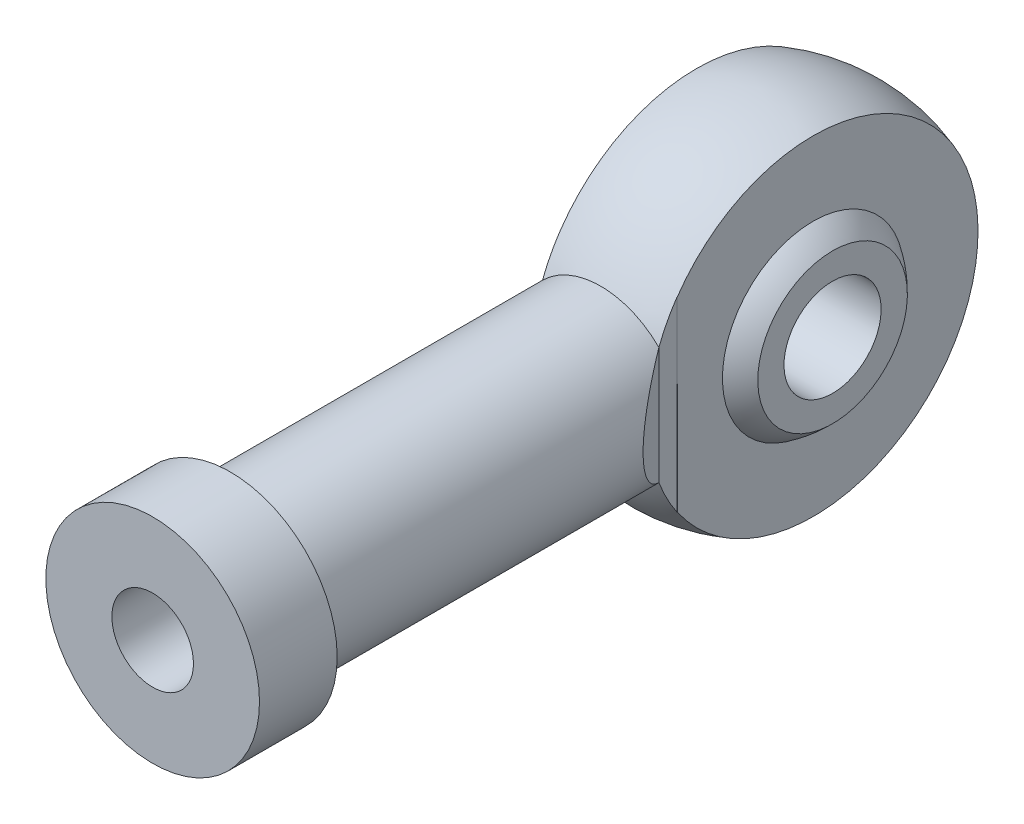
from build123d import *

# Parameters (mm, degrees)
SKETCH_3_R             = 5.5
EXTRUDE_2_DEPTH        = 4
SKETCH_4_R             = 4.25
EXTRUDE_3_DEPTH        = 20
CUT_EXTRUDE_1_DEPTH    = 10
HOLE_WIZARD_M5_1_D     = 4.2
HOLE_WIZARD_M5_1_DEPTH = 12.4
HOLE_WIZARD_M5_1_TIP   = 1.2618073


with BuildPart() as part:
    # 草图1 → 旋转1 (revolve)
    with BuildSketch(Plane.XY):
        with BuildLine():
            Line((-4, 3.854610875), (-4, 2.495599217))
            Line((-4, 2.495599217), (4, 2.504403811))
            Line((4, 2.504403811), (4, 3.854610875))
            ThreePointArc((4, 3.854610875), (3.523970046, 4.294142536), (3, 4.675256677))
            Line((3, 4.675256677), (3, 8.485281374))
            ThreePointArc((3, 8.485281374), (0, 9), (-3, 8.485281374))
            Line((-3, 8.485281374), (-3, 4.675256677))
            ThreePointArc((-3, 4.675256677), (-3.523970046, 4.294142536), (-4, 3.854610875))
        make_face()
    revolve(axis=Axis((3.999995155, 0.004402291, 0), (-0.999999394, -0.001100574, 0)))



with BuildPart() as body_2:
    # 草图3 → 凸台-拉伸2 (new body)
    with BuildSketch(Plane.XY.offset(27)):
        Circle(SKETCH_3_R)
    extrude(amount=EXTRUDE_2_DEPTH)


with BuildPart() as part_1:
    add(part.part)

    add(body_2.part)  # 凸台-拉伸3 merges body 2
    # 草图4 → 凸台-拉伸3 (add)
    with BuildSketch(Plane(origin=(0, 0, 27), x_dir=(-1, 0, 0), z_dir=(0, 0, -1))):
        Circle(SKETCH_4_R)
    extrude(amount=EXTRUDE_3_DEPTH)

    # 草图5 → 切除-拉伸1 (cut, symmetric)
    with BuildSketch(Plane(origin=(0, 0, 0), x_dir=(1, 0, 0), z_dir=(0, 1, 0))):
        Polygon((-2.994932477, -7), (-2.994932477, -7.933315826), (-4.25, -10), (-4.25, -7), align=None)
        Polygon((4.25, -7), (2.994932477, -7), (2.994932477, -7.933315826), (4.25, -10), align=None)
    extrude(amount=CUT_EXTRUDE_1_DEPTH, both=True, mode=Mode.SUBTRACT)

    # M5 螺纹孔1
    with Locations(Plane.XY.offset(31)):
        with Locations((0, 0)):
            Hole(HOLE_WIZARD_M5_1_D / 2, depth=HOLE_WIZARD_M5_1_DEPTH)
            with Locations((0, 0, -(HOLE_WIZARD_M5_1_DEPTH + HOLE_WIZARD_M5_1_TIP / 2))):  # 118° drill point
                Cone(0, HOLE_WIZARD_M5_1_D / 2, HOLE_WIZARD_M5_1_TIP, mode=Mode.SUBTRACT)


solid = part_1.part
